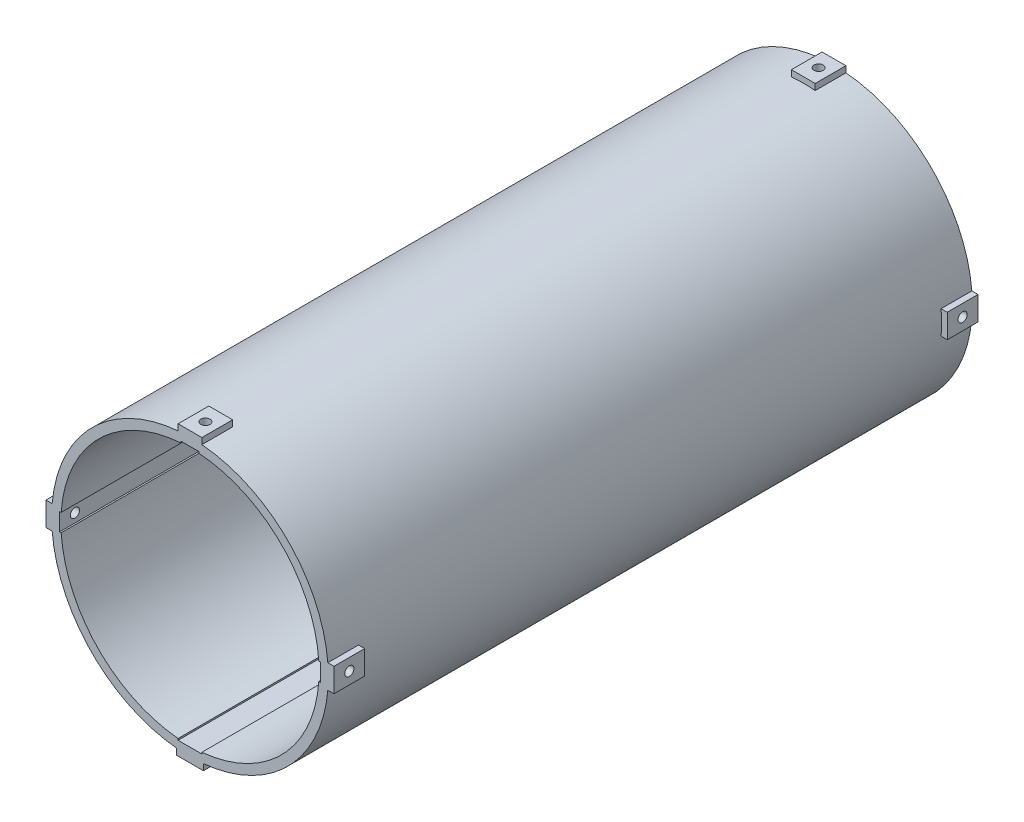
from build123d import *
from build123d.topology import SkipClean

# Parameters (mm, degrees)
EXTRUDE_1_DEPTH          = 419
CUT_EXTRUDE_START        = -399
SKETCH_2_R               = 110
SKETCH_2_R_2             = 90
CUT_EXTRUDE_1_DEPTH      = 379
SKETCH_3_R               = 84
CUT_EXTRUDE_2_DEPTH      = 440.444628006
SKETCH_4_W               = 15.5
SKETCH_4_H               = 1
SKETCH_4_W_2             = 1
SKETCH_4_H_2             = 11.5
SKETCH_4_W_3             = 11.5
CUT_EXTRUDE_3_DEPTH      = 440.444628006
SKETCH_5_R               = 3
CUT_EXTRUDE_4_DEPTH      = 465.963674458
PATTERN_CIRCULAR_1_COUNT = 4


with BuildPart() as part:
    # Sketch 1 → Extrude 1 (new body)
    with BuildSketch(Plane.XY):
        with BuildLine():
            Line((-8.75, -89.573642887), (-8.75, -93.587458654))
            Line((-8.75, -93.587458654), (8.75, -93.587458654))
            Line((8.75, -93.587458654), (8.75, -89.573642887))
            ThreePointArc((8.75, -89.573642887), (63.993668164, -63.283571604), (89.66569857, -7.75))
            Line((89.66569857, -7.75), (93.676520759, -7.75))
            Line((93.676520759, -7.75), (93.676520759, 7.75))
            Line((93.676520759, 7.75), (89.66569857, 7.75))
            ThreePointArc((89.66569857, 7.75), (63.639610307, 63.639610307), (7.75, 89.66569857))
            Line((7.75, 89.66569857), (7.75, 93.676520759))
            Line((7.75, 93.676520759), (-7.75, 93.676520759))
            Line((-7.75, 93.676520759), (-7.75, 89.66569857))
            ThreePointArc((-7.75, 89.66569857), (-63.639610307, 63.639610307), (-89.66569857, 7.75))
            Line((-89.66569857, 7.75), (-93.676520759, 7.75))
            Line((-93.676520759, 7.75), (-93.676520759, -7.75))
            Line((-93.676520759, -7.75), (-89.66569857, -7.75))
            ThreePointArc((-89.66569857, -7.75), (-63.993668164, -63.283571604), (-8.75, -89.573642887))
        make_face()
    extrude(amount=EXTRUDE_1_DEPTH)

    # Sketch 2 → Cut-Extrude 1 (cut)
    with SkipClean():  # the faces are left unmerged after this step: merging them gives an invalid solid
        with BuildSketch(Plane.XY.offset(419).offset(CUT_EXTRUDE_START)):
            Circle(SKETCH_2_R)
            with Locations(Location((0, 0, 0), (0, 0, 184.939921132))):
                Circle(SKETCH_2_R_2, mode=Mode.SUBTRACT)
        extrude(amount=CUT_EXTRUDE_1_DEPTH, mode=Mode.SUBTRACT)

    # Sketch 3 → Cut-Extrude 2 (cut, through all)
    with SkipClean():  # the faces are left unmerged after this step: merging them gives an invalid solid
        with BuildSketch(Plane.XY.offset(419)):
            Circle(SKETCH_3_R)
        extrude(amount=-CUT_EXTRUDE_2_DEPTH, mode=Mode.SUBTRACT)

    # Sketch 4 → Cut-Extrude 3 (cut, through all)
    with SkipClean():  # the faces are left unmerged after this step: merging them gives an invalid solid
        with BuildSketch(Plane.XY.offset(419)):
            with Locations((0, -84.141721049)):
                Rectangle(SKETCH_4_W, SKETCH_4_H)
            with Locations((-84.302968325, 0)):
                Rectangle(SKETCH_4_W_2, SKETCH_4_H_2)
            with Locations((0, 84.302968325)):
                Rectangle(SKETCH_4_W_3, SKETCH_4_H)
            with Locations((84.302968325, 0)):
                Rectangle(SKETCH_4_W_2, SKETCH_4_H_2)
        extrude(amount=-CUT_EXTRUDE_3_DEPTH, mode=Mode.SUBTRACT)

    # Sketch 5 → Cut-Extrude 4 (cut, through all)
    with SkipClean():  # the faces are left unmerged after this step: merging them gives an invalid solid
        with BuildSketch(Plane(origin=(-84.802968325, 0, 0), x_dir=(0, 0, -1), z_dir=(1, 0, 0))):
            with Locations((-409, 0)):
                Circle(SKETCH_5_R)
            with Locations((-10, 0)):
                Circle(SKETCH_5_R)
        cut_extrude_4 = extrude(amount=-CUT_EXTRUDE_4_DEPTH, mode=Mode.SUBTRACT)

    # Pattern Circular 1: Cut-Extrude 4 ×4 about axis
    with SkipClean():  # the faces are left unmerged after this step: merging them gives an invalid solid
        pattern_circular_1_axis = Axis((0, 0, 1000), (0, 0, -1))
        for i in range(1, PATTERN_CIRCULAR_1_COUNT):
            add(cut_extrude_4.rotate(pattern_circular_1_axis, i * 360 / PATTERN_CIRCULAR_1_COUNT), mode=Mode.SUBTRACT)


solid = part.part
